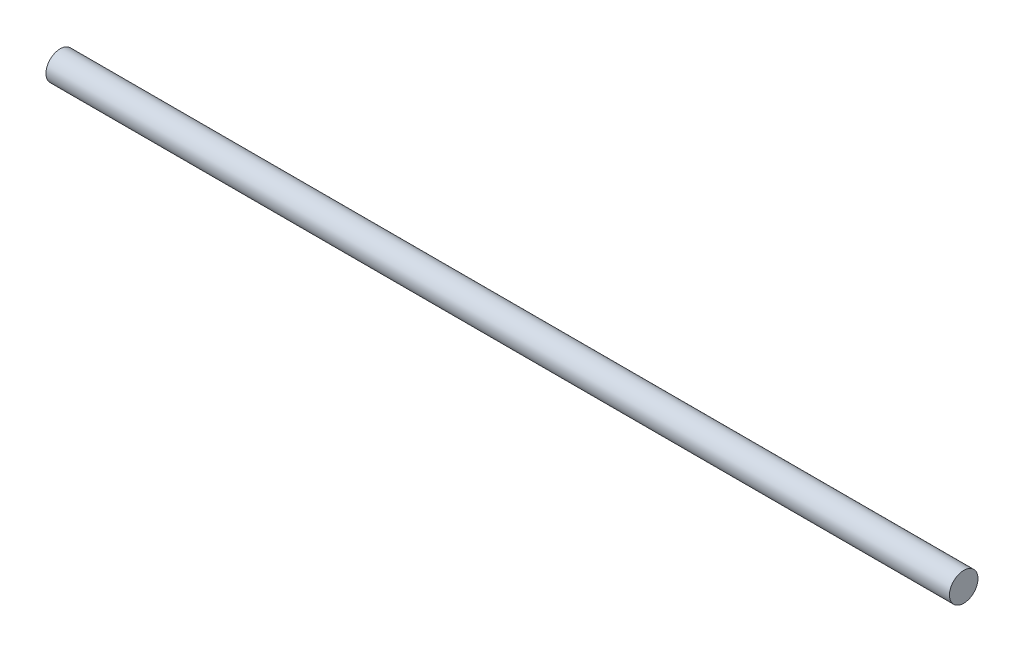
from build123d import *

# Parameters (mm, degrees)
SKETCH1_R           = 3
BOSS_EXTRUDE1_DEPTH = 190


with BuildPart() as part:
    # Sketch1 → Boss-Extrude1 (new body)
    with BuildSketch(Plane(origin=(0, 0, 0), x_dir=(0, 0, -1), z_dir=(1, 0, 0))):
        Circle(SKETCH1_R)
    extrude(amount=BOSS_EXTRUDE1_DEPTH)


solid = part.part
